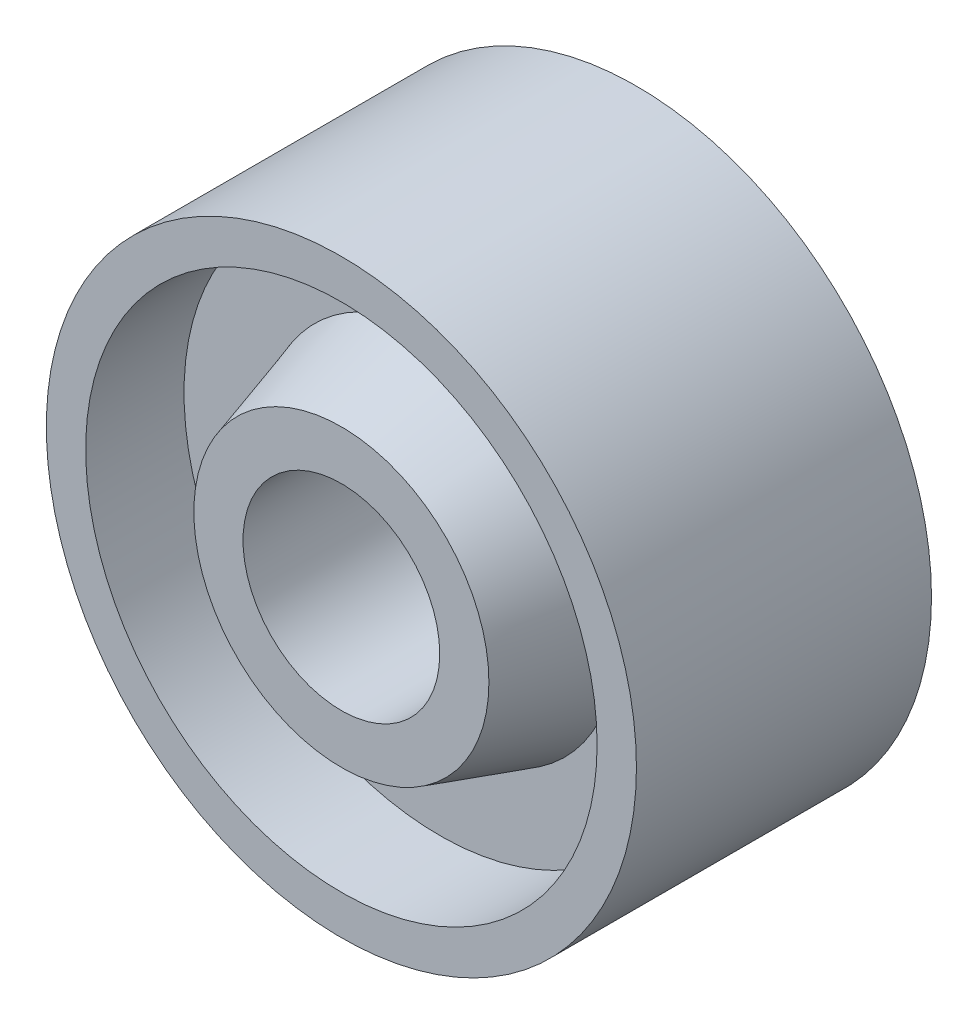
from build123d import *

# Parameters (mm, degrees)
IZIM1_R                     = 30
Y_KSEKLIK_EKSTR_ZYON1_DEPTH = 30
IZIM2_R                     = 26
KES_EKSTR_ZYON1_DEPTH       = 10
IZIM3_R                     = 26
KES_EKSTR_ZYON2_DEPTH       = 10
IZIM4_R                     = 10
KES_EKSTR_ZYON3_DEPTH       = 10
IZIM6_R                     = 15
Y_KSEKLIK_EKSTR_ZYON3_DEPTH = 10
IZIM7_R                     = 10
KES_EKSTR_ZYON4_DEPTH       = 10
IZIM8_R                     = 15
Y_KSEKLIK_EKSTR_ZYON4_DEPTH = 10
IZIM9_R                     = 10
KES_EKSTR_ZYON5_DEPTH       = 10


with BuildPart() as part:
    # Çizim1 → Yükseklik-Ekstrüzyon1 (new body)
    with BuildSketch(Plane.XY):
        Circle(IZIM1_R)
    extrude(amount=-Y_KSEKLIK_EKSTR_ZYON1_DEPTH)

    # Çizim2 → Kes-Ekstrüzyon1 (cut)
    with BuildSketch(Plane.XY):
        Circle(IZIM2_R)
    extrude(amount=-KES_EKSTR_ZYON1_DEPTH, mode=Mode.SUBTRACT)

    # Çizim3 → Kes-Ekstrüzyon2 (cut)
    with BuildSketch(Plane(origin=(0, 0, -30), x_dir=(-1, 0, 0), z_dir=(0, 0, -1))):
        Circle(IZIM3_R)
    extrude(amount=-KES_EKSTR_ZYON2_DEPTH, mode=Mode.SUBTRACT)

    # Çizim4 → Kes-Ekstrüzyon3 (cut)
    with BuildSketch(Plane.XY.offset(-10)):
        Circle(IZIM4_R)
    extrude(amount=-KES_EKSTR_ZYON3_DEPTH, mode=Mode.SUBTRACT)

    # Çizim6 → Yükseklik-Ekstrüzyon3 (add)
    with BuildSketch(Plane.XY.offset(-10)):
        Circle(IZIM6_R)
    extrude(amount=Y_KSEKLIK_EKSTR_ZYON3_DEPTH)

    # Çizim7 → Kes-Ekstrüzyon4 (cut)
    with BuildSketch(Plane.XY):
        Circle(IZIM7_R)
    extrude(amount=-KES_EKSTR_ZYON4_DEPTH, mode=Mode.SUBTRACT)

    # Çizim8 → Yükseklik-Ekstrüzyon4 (add)
    with BuildSketch(Plane(origin=(0, 0, -20), x_dir=(-1, 0, 0), z_dir=(0, 0, -1))):
        Circle(IZIM8_R)
    extrude(amount=Y_KSEKLIK_EKSTR_ZYON4_DEPTH)

    # Çizim9 → Kes-Ekstrüzyon5 (cut)
    with BuildSketch(Plane(origin=(0, 0, -30), x_dir=(-1, 0, 0), z_dir=(0, 0, -1))):
        Circle(IZIM9_R)
    extrude(amount=-KES_EKSTR_ZYON5_DEPTH, mode=Mode.SUBTRACT)

    # Çizim12 → Döndür1 (revolve)
    with BuildSketch(Plane(origin=(0, 0, 0), x_dir=(0, 0, -1), z_dir=(1, 0, 0))):
        Polygon((10, 18), (0, 15), (10, 15), align=None)
    d_nd_r1 = revolve(axis=Axis((0, 0, 0), (0, 0, -1)))

    # Aynalama1: Döndür1 across plane
    add(d_nd_r1.mirror(Plane.XY.offset(-15)))


solid = part.part
